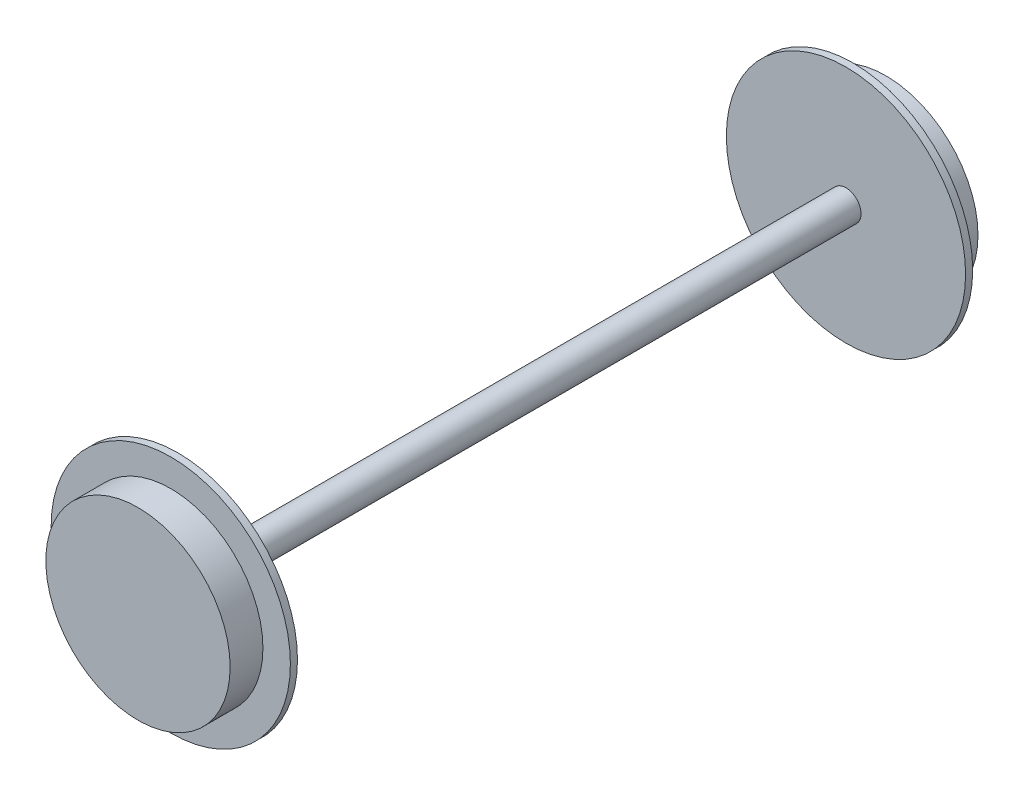
from build123d import *


with BuildPart() as part:
    # Эскиз1 → Повернуть2 (revolve)
    with BuildSketch(Plane(origin=(0, 0, 0), x_dir=(0, 0, -1), z_dir=(1, 0, 0))):
        Polygon((0, 8.5), (188.5, 8.5), (188.5, 67.5), (192.5, 67.5), (192.5, 52), (211, 52), (211, 0), (0, 0), align=None)
    revolve_2 = revolve(axis=Axis((0, 0, 0), (0, 0, -1)))

    # Зеркальное отражение1: Повернуть2 across plane
    add(revolve_2.mirror(Plane(origin=(0, 8.5, 0), x_dir=(1, 0, 0), z_dir=(0, 0, -1))))


solid = part.part
